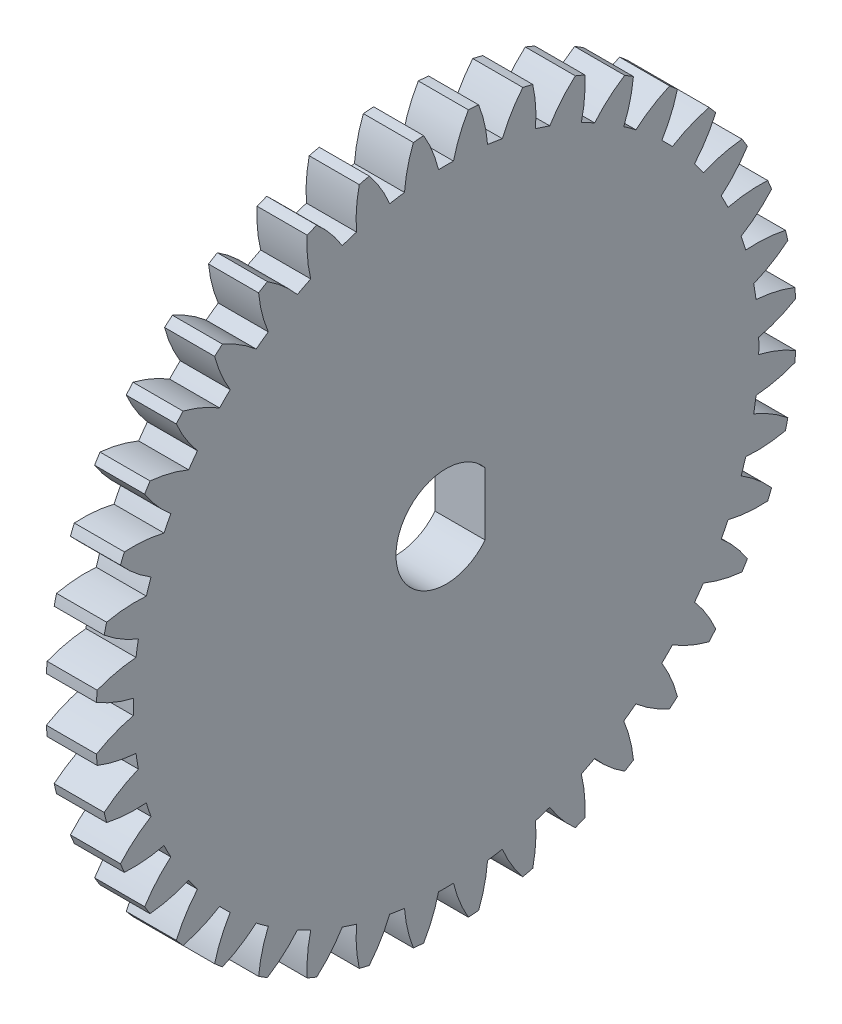
from build123d import *

# Parameters (mm, degrees)
BASPROSKE_W        = 3
BASPROSKE_H        = 21
TOOTHCUT_DEPTH     = 30.849623113
TEETHCUTS_COUNT    = 40
TEETHCUTS_ANGLE    = 351
BORSKE_R           = 1.5
BORE_DEPTH         = 50.0012192
CUT_EXTRUDE1_DEPTH = 30.78938648


with BuildPart() as part:
    # BasProSke → Base-Revolve (revolve)
    with BuildSketch(Plane(origin=(0, 0, 0), x_dir=(1, 0, 0), z_dir=(0, 1, 0)), mode=Mode.PRIVATE) as base_revolve_sk:
        with Locations((1.5, 10.5)):
            Rectangle(BASPROSKE_W, BASPROSKE_H)
    revolve(base_revolve_sk.sketch.rotate(Axis((-10, 0, 0), (1, 0, 0)), 180), axis=Axis((-10, 0, 0), (1, 0, 0)))

    # TooCutSke → ToothCut (cut, through all)
    with BuildSketch(Plane(origin=(0, 0, 0), x_dir=(0, 0, -1), z_dir=(1, 0, 0))):
        with BuildLine():
            ThreePointArc((0.448673268, 18.74363074), (0, 18.749), (-0.448673268, 18.74363074))
            ThreePointArc((-0.448673268, 18.74363074), (-0.816786816, 19.89705013), (-1.354745081, 20.981708961))
            ThreePointArc((-1.354745081, 20.981708961), (0, 21.0254), (1.354745081, 20.981708961))
            ThreePointArc((1.354745081, 20.981708961), (0.816786816, 19.89705013), (0.448673268, 18.74363074))
        make_face()
    toothcut = extrude(amount=TOOTHCUT_DEPTH, mode=Mode.SUBTRACT)

    # TeethCuts: ToothCut ×40 about axis
    teethcuts_axis = Axis((-10, 0, 0), (1, 0, 0))
    for i in range(1, TEETHCUTS_COUNT):
        add(toothcut.rotate(teethcuts_axis, i * TEETHCUTS_ANGLE / (TEETHCUTS_COUNT - 1)), mode=Mode.SUBTRACT)

    # BorSke → Bore (cut, symmetric)
    with BuildSketch(Plane(origin=(0, 0, 0), x_dir=(0, 0, -1), z_dir=(1, 0, 0))):
        with Locations(Location((0, 0, 0), (0, 0, 180))):
            Circle(BORSKE_R)
    extrude(amount=BORE_DEPTH, both=True, mode=Mode.SUBTRACT)

    # Sketch1 → Cut-Extrude1 (cut, through all)
    with BuildSketch(Plane(origin=(3, 0, 0), x_dir=(0, 0, -1), z_dir=(1, 0, 0))):
        with BuildLine():
            Line((2.341874249, -1.875), (2.341874249, 1.875))
            ThreePointArc((2.341874249, 1.875), (-3, 0), (2.341874249, -1.875))
        make_face()
    extrude(amount=-CUT_EXTRUDE1_DEPTH, mode=Mode.SUBTRACT)


solid = part.part
